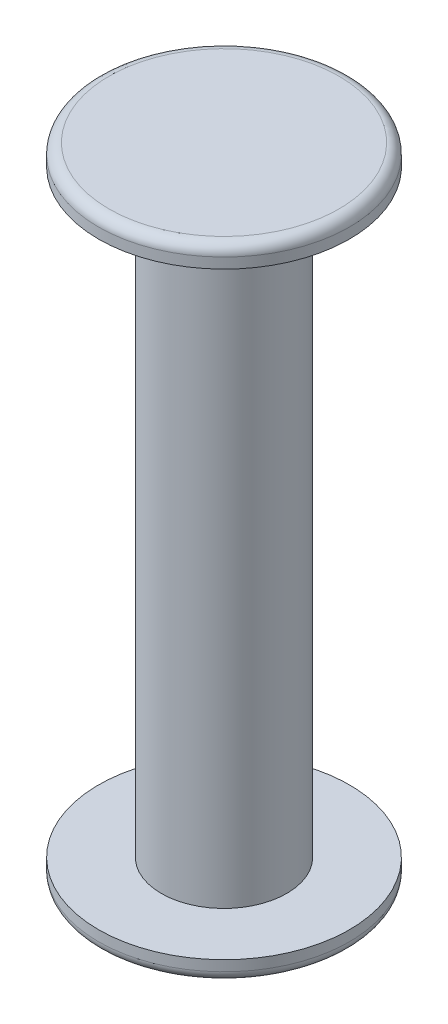
from build123d import *

# Parameters (mm, degrees)
SKETCH_1_R             = 3
EXTRUDE_1_DEPTH        = 14.3
SKETCH_2_R             = 6
EXTRUDE_2_DEPTH        = 1
FILLET_1_R             = 0.5
FILLET_1_OF_MIRROR_1_R = 0.5


with BuildPart() as part:
    # 草图1 → 凸台-拉伸1 (new body, symmetric)
    with BuildSketch(Plane(origin=(0, 0, 0), x_dir=(1, 0, 0), z_dir=(0, 1, 0))):
        Circle(SKETCH_1_R)
    extrude(amount=EXTRUDE_1_DEPTH, both=True)

    # 草图2 → 凸台-拉伸2 (add)
    with BuildSketch(Plane(origin=(0, 14.3, 0), x_dir=(1, 0, 0), z_dir=(0, 1, 0))):
        Circle(SKETCH_2_R)
    extrude_2 = extrude(amount=EXTRUDE_2_DEPTH)

    # 圆角1
    fillet_1_edges = [part.edges().sort_by_distance(p)[0] for p in [
        (-6, 15.3, 0),
    ]]
    fillet(fillet_1_edges, radius=FILLET_1_R)

    # 镜向1: 凸台-拉伸2 across plane
    add(extrude_2.mirror(Plane.ZX))

    # 圆角1 of 镜向1
    fillet_1_of_mirror_1_edges = [part.edges().sort_by_distance(p)[0] for p in [
        (-6, -15.3, 0),
    ]]
    fillet(fillet_1_of_mirror_1_edges, radius=FILLET_1_OF_MIRROR_1_R)


solid = part.part
